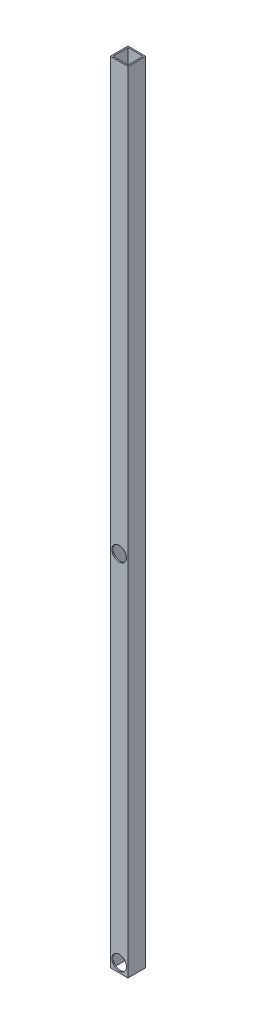
from build123d import *

# Parameters (mm, degrees)
SKETCH1_W           = 44.45
SKETCH1_H           = 44.45
SKETCH1_W_2         = 38.1
SKETCH1_H_2         = 38.1
BOSS_EXTRUDE1_DEPTH = 1981.2
CUT_EXTRUDE1_REACH  = 46.45
SKETCH2_R           = 18.25625
CUT_EXTRUDE2_REACH  = 46.45
SKETCH4_R           = 12.7


with BuildPart() as part:
    # Sketch1 → Boss-Extrude1 (new body)
    with BuildSketch(Plane(origin=(0, 0, 0), x_dir=(1, 0, 0), z_dir=(0, 1, 0))):
        with Locations((22.225, 22.225)):
            Rectangle(SKETCH1_W, SKETCH1_H)
        with Locations((22.225, 22.225)):
            Rectangle(SKETCH1_W_2, SKETCH1_H_2, mode=Mode.SUBTRACT)
    extrude(amount=BOSS_EXTRUDE1_DEPTH)

    # Sketch2 → Cut-Extrude1 (cut, up to next)
    with BuildSketch(Plane.XY, mode=Mode.PRIVATE) as cut_extrude1_sk1:
        with Locations((22.225, 22.225)):
            Circle(SKETCH2_R)
    cut_extrude1_tool1 = extrude(cut_extrude1_sk1.sketch, amount=-CUT_EXTRUDE1_REACH, mode=Mode.PRIVATE) & part.part
    add(cut_extrude1_tool1.solids().sort_by_distance((22.225, 22.225, 0))[0], mode=Mode.SUBTRACT)
    # Sketch2 → Cut-Extrude1 (cut, up to next)
    with BuildSketch(Plane.XY, mode=Mode.PRIVATE) as cut_extrude1_sk2:
        with Locations((22.225, 911.225)):
            Circle(SKETCH2_R)
    cut_extrude1_tool2 = extrude(cut_extrude1_sk2.sketch, amount=-CUT_EXTRUDE1_REACH, mode=Mode.PRIVATE) & part.part
    add(cut_extrude1_tool2.solids().sort_by_distance((22.225, 911.225, 0))[0], mode=Mode.SUBTRACT)

    # Sketch4 → Cut-Extrude2 (cut, up to next)
    with BuildSketch(Plane(origin=(0, 0, -44.45), x_dir=(-1, 0, 0), z_dir=(0, 0, -1)), mode=Mode.PRIVATE) as cut_extrude2_sk1:
        with Locations((-22.225, 911.225)):
            Circle(SKETCH4_R)
    cut_extrude2_tool1 = extrude(cut_extrude2_sk1.sketch, amount=-CUT_EXTRUDE2_REACH, mode=Mode.PRIVATE) & part.part
    add(cut_extrude2_tool1.solids().sort_by_distance((22.225, 911.225, -44.45))[0], mode=Mode.SUBTRACT)
    # Sketch4 → Cut-Extrude2 (cut, up to next)
    with BuildSketch(Plane(origin=(0, 0, -44.45), x_dir=(-1, 0, 0), z_dir=(0, 0, -1)), mode=Mode.PRIVATE) as cut_extrude2_sk2:
        with Locations((-22.225, 22.225)):
            Circle(SKETCH4_R)
    cut_extrude2_tool2 = extrude(cut_extrude2_sk2.sketch, amount=-CUT_EXTRUDE2_REACH, mode=Mode.PRIVATE) & part.part
    add(cut_extrude2_tool2.solids().sort_by_distance((22.225, 22.225, -44.45))[0], mode=Mode.SUBTRACT)


solid = part.part
